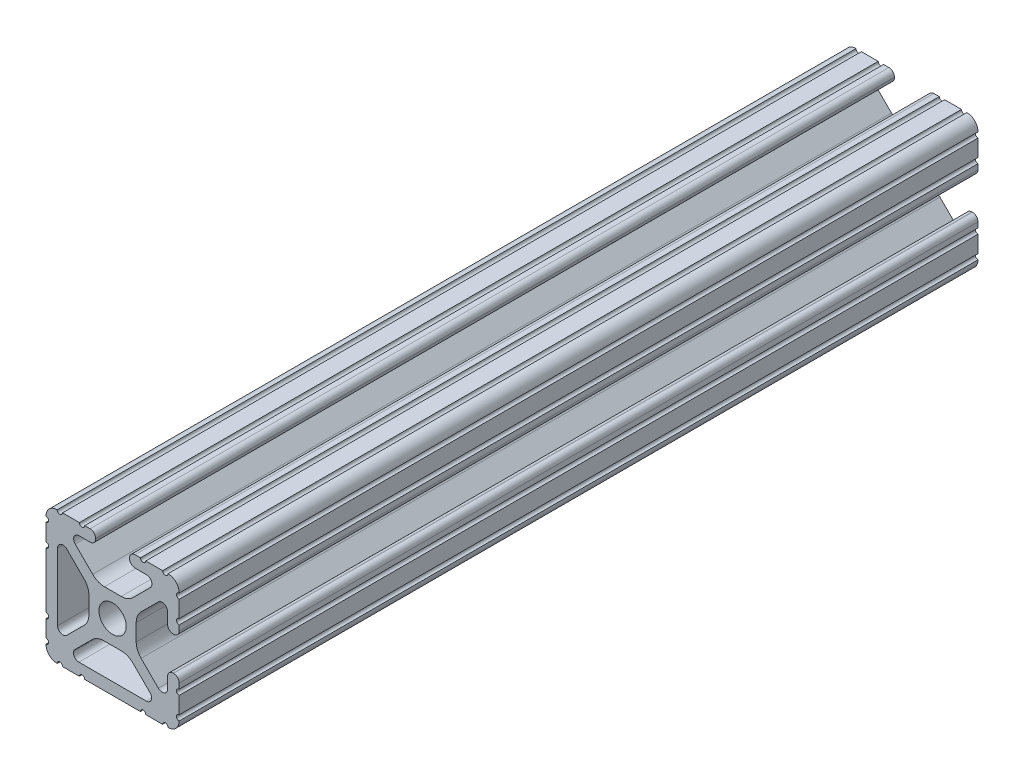
from build123d import *

# Parameters (mm, degrees)
SKETCH3_R                = 2.6035
BOSS_EXTRUDE1_DEPTH      = 76.2
BOSS_EXTRUDE1_DEPTH_BACK = 76.2


with BuildPart() as part:
    # Sketch3 → Boss-Extrude1 (new body, two sides)
    with BuildSketch(Plane.XY) as boss_extrude1_sk:
        with BuildLine():
            Line((6.3331344, -12.7), (9.5504, -12.7))
            ThreePointArc((9.5504, -12.7), (10.058323491, -12.192000006), (10.566399977, -12.699846982))
            ThreePointArc((10.566399977, -12.699846982), (12.082522516, -12.082522516), (12.699846982, -10.566399977))
            ThreePointArc((12.699846982, -10.566399977), (12.192000006, -10.058323491), (12.7, -9.5504))
            Line((12.7, -9.5504), (12.7, -6.3330836))
            ThreePointArc((12.7, -6.3330836), (12.192, -5.8250836), (12.7, -5.3170836))
            Line((12.7, -5.3170836), (12.7, -4.28752))
            ThreePointArc((12.7, -4.28752), (12.392749156, -3.545750844), (11.65098, -3.2385))
            Line((11.65098, -3.2385), (11.53922, -3.2385))
            ThreePointArc((11.53922, -3.2385), (10.797450844, -3.545750844), (10.4902, -4.28752))
            Line((10.4902, -4.28752), (10.4902, -6.402089023))
            ThreePointArc((10.4902, -6.402089023), (9.856394933, -7.351113629), (8.736962546, -7.129240479))
            Line((8.736962546, -7.129240479), (5.440484187, -3.838768792))
            ThreePointArc((5.440484187, -3.838768792), (4.75073678, -2.808015636), (4.5085, -1.591658411))
            Line((4.5085, -1.591658411), (4.5085, 1.591658411))
            ThreePointArc((4.5085, 1.591658411), (4.75073678, 2.808015636), (5.440484187, 3.838768792))
            Line((5.440484187, 3.838768792), (8.736962546, 7.129240479))
            ThreePointArc((8.736962546, 7.129240479), (9.856394933, 7.351113629), (10.4902, 6.402089023))
            Line((10.4902, 6.402089023), (10.4902, 4.28752))
            ThreePointArc((10.4902, 4.28752), (10.797450844, 3.545750844), (11.53922, 3.2385))
            Line((11.53922, 3.2385), (11.65098, 3.2385))
            ThreePointArc((11.65098, 3.2385), (12.392749156, 3.545750844), (12.7, 4.28752))
            Line((12.7, 4.28752), (12.7, 5.3171344))
            ThreePointArc((12.7, 5.3171344), (12.192, 5.8251344), (12.7, 6.3331344))
            Line((12.7, 6.3331344), (12.7, 9.5504))
            ThreePointArc((12.7, 9.5504), (12.192000006, 10.058323491), (12.699846982, 10.566399977))
            ThreePointArc((12.699846982, 10.566399977), (12.082522516, 12.082522516), (10.566399977, 12.699846982))
            ThreePointArc((10.566399977, 12.699846982), (10.058323491, 12.192000006), (9.5504, 12.7))
            Line((9.5504, 12.7), (6.3330836, 12.7))
            ThreePointArc((6.3330836, 12.7), (5.8250836, 12.192), (5.3170836, 12.7))
            Line((5.3170836, 12.7), (4.28752, 12.7))
            ThreePointArc((4.28752, 12.7), (3.545750844, 12.392749156), (3.2385, 11.65098))
            Line((3.2385, 11.65098), (3.2385, 11.53922))
            ThreePointArc((3.2385, 11.53922), (3.545750844, 10.797450844), (4.28752, 10.4902))
            Line((4.28752, 10.4902), (6.476795923, 10.4902))
            ThreePointArc((6.476795923, 10.4902), (7.432175542, 9.851520654), (7.207206853, 8.724555432))
            Line((7.207206853, 8.724555432), (3.900315394, 5.423689619))
            ThreePointArc((3.900315394, 5.423689619), (2.8709819, 4.736928798), (1.657299581, 4.4958))
            Line((1.657299581, 4.4958), (-1.553667902, 4.4958))
            ThreePointArc((-1.553667902, 4.4958), (-2.767350221, 4.736928798), (-3.796683715, 5.423689619))
            Line((-3.796683715, 5.423689619), (-7.134200223, 8.755124678))
            ThreePointArc((-7.134200223, 8.755124678), (-7.355273948, 9.862578342), (-6.416435163, 10.4902))
            Line((-6.416435163, 10.4902), (-4.28752, 10.4902))
            ThreePointArc((-4.28752, 10.4902), (-3.545750844, 10.797450844), (-3.2385, 11.53922))
            Line((-3.2385, 11.53922), (-3.2385, 11.65098))
            ThreePointArc((-3.2385, 11.65098), (-3.545750844, 12.392749156), (-4.28752, 12.7))
            Line((-4.28752, 12.7), (-5.3171344, 12.7))
            ThreePointArc((-5.3171344, 12.7), (-5.8251344, 12.192), (-6.3331344, 12.7))
            Line((-6.3331344, 12.7), (-9.5504, 12.7))
            ThreePointArc((-9.5504, 12.7), (-10.058323491, 12.192000006), (-10.566399977, 12.699846982))
            ThreePointArc((-10.566399977, 12.699846982), (-12.082522516, 12.082522516), (-12.699846982, 10.566399977))
            ThreePointArc((-12.699846982, 10.566399977), (-12.192000006, 10.058323491), (-12.7, 9.5504))
            Line((-12.7, 9.5504), (-12.7, 6.3331344))
            ThreePointArc((-12.7, 6.3331344), (-12.192, 5.8251344), (-12.7, 5.3171344))
            Line((-12.7, 5.3171344), (-12.7, -5.3170836))
            ThreePointArc((-12.7, -5.3170836), (-12.192, -5.8250836), (-12.7, -6.3330836))
            Line((-12.7, -6.3330836), (-12.7, -9.5504))
            ThreePointArc((-12.7, -9.5504), (-12.192000006, -10.058323491), (-12.699846982, -10.566399977))
            ThreePointArc((-12.699846982, -10.566399977), (-12.082522516, -12.082522516), (-10.566399977, -12.699846982))
            ThreePointArc((-10.566399977, -12.699846982), (-10.058323491, -12.192000006), (-9.5504, -12.7))
            Line((-9.5504, -12.7), (-6.3330836, -12.7))
            ThreePointArc((-6.3330836, -12.7), (-5.8250836, -12.192), (-5.3170836, -12.7))
            Line((-5.3170836, -12.7), (5.3171344, -12.7))
            ThreePointArc((5.3171344, -12.7), (5.8251344, -12.192), (6.3331344, -12.7))
        make_face()
        Circle(SKETCH3_R, mode=Mode.SUBTRACT)
        with BuildLine():
            Line((-8.753441447, -7.145689354), (-5.440484187, -3.838768792))
            ThreePointArc((-5.440484187, -3.838768792), (-4.75073678, -2.808015636), (-4.5085, -1.591658411))
            Line((-4.5085, -1.591658411), (-4.5085, 1.591658411))
            ThreePointArc((-4.5085, 1.591658411), (-4.75073678, 2.808015636), (-5.440484187, 3.838768792))
            Line((-5.440484187, 3.838768792), (-8.736962546, 7.129240479))
            ThreePointArc((-8.736962546, 7.129240479), (-9.856394933, 7.351113629), (-10.4902, 6.402089023))
            Line((-10.4902, 6.402089023), (-10.4902, -6.425372487))
            ThreePointArc((-10.4902, -6.425372487), (-9.862352148, -7.36547709), (-8.753441447, -7.145689354))
        make_face(mode=Mode.SUBTRACT)
        with BuildLine():
            Line((7.147805753, -8.66526257), (3.900315394, -5.423689619))
            ThreePointArc((3.900315394, -5.423689619), (2.8709819, -4.736928798), (1.657299581, -4.4958))
            Line((1.657299581, -4.4958), (-1.657299581, -4.4958))
            ThreePointArc((-1.657299581, -4.4958), (-2.8709819, -4.736928798), (-3.900315394, -5.423689619))
            Line((-3.900315394, -5.423689619), (-7.153722341, -8.671168377))
            ThreePointArc((-7.153722341, -8.671168377), (-7.374796065, -9.77862204), (-6.435957281, -10.406243698))
            Line((-6.435957281, -10.406243698), (6.427597582, -10.406243698))
            ThreePointArc((6.427597582, -10.406243698), (7.369631963, -9.776485757), (7.147805753, -8.66526257))
        make_face(mode=Mode.SUBTRACT)
    extrude(amount=BOSS_EXTRUDE1_DEPTH)
    extrude(boss_extrude1_sk.sketch, amount=-BOSS_EXTRUDE1_DEPTH_BACK)


solid = part.part
